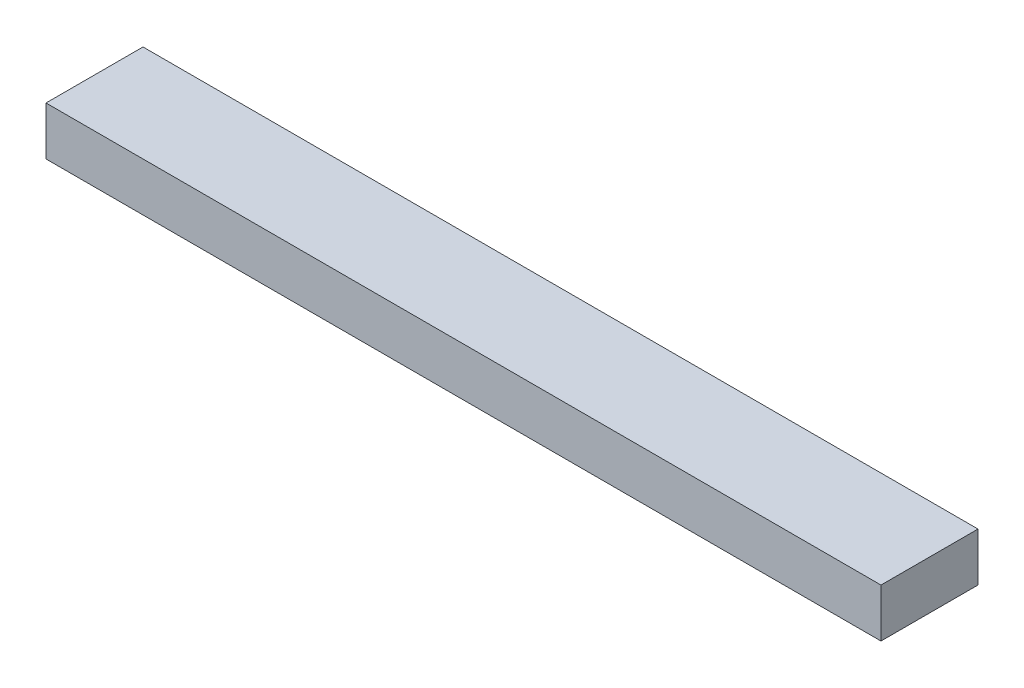
from build123d import *

# Parameters (mm, degrees)
SKETCH1_W           = 874.395
SKETCH1_H           = 101.6
BOSS_EXTRUDE1_DEPTH = 25.4


with BuildPart() as part:
    # Sketch1 → Boss-Extrude1 (new body, symmetric)
    with BuildSketch(Plane(origin=(0, 0, 0), x_dir=(1, 0, 0), z_dir=(0, 1, 0))):
        Rectangle(SKETCH1_W, SKETCH1_H)
    extrude(amount=BOSS_EXTRUDE1_DEPTH, both=True)


solid = part.part
